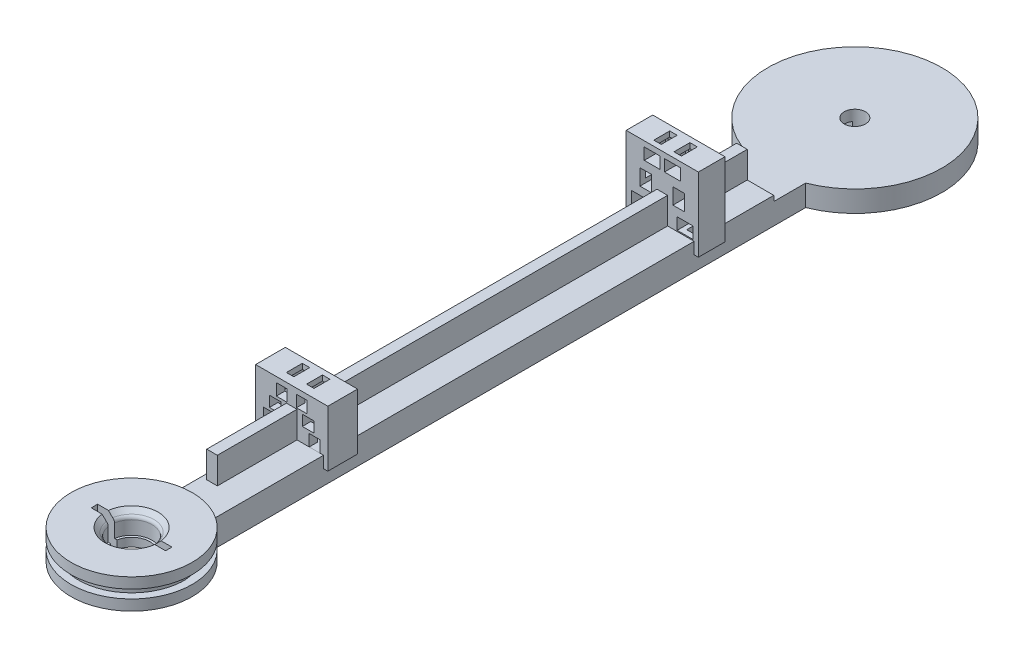
from build123d import *

# Parameters (mm, degrees)
SKETCH1_R                       = 5
ELBOWPULLEYMIDSECTION_DEPTH     = 0.8
SKETCH8_R                       = 1.925
BALLBEARINGSLOT_DEPTH           = 9.533463541
BALLBEARINGSTOPPER_START        = -0.8
SKETCH10_R                      = 1.925
SKETCH10_R_2                    = 1.7
BALLBEARINGSTOPPER_DEPTH        = 0.8
SKETCH25_W                      = 3.5
SKETCH25_H                      = 0.6
DEFORMATIONCUT_DEPTH            = 9.533463541
CIRPATTERN1_COUNT               = 2
CABLESLOT_DEPTH                 = 0.8
BONE_DEPTH                      = 1.25
CLEARANCECUT_REACH              = 62.794
CABLECLEARANCECUT_START         = -1.65
CABLECLEARANCECUT_DEPTH         = 0.8
FINGERHOLDERMOUTH_START         = -1.25
FINGERHOLDERMOUTH_DEPTH         = 2
SKETCH18_R                      = 1
FINGERAXLEHOLE_DEPTH            = 2
FINGERAXLELOCK_DEPTH            = 1
SKETCH19_W                      = 6.8
SKETCH19_H                      = 4.2
TUBECLIPSHOLDERBASE_DEPTH       = 2.8
TUBECLIPENTRANCES_START         = -0.8
SKETCH19_3_W                    = 0.25
SKETCH19_3_H                    = 1.1
SKETCH19_3_W_2                  = 1.1
SKETCH19_3_H_2                  = 1
TUBECLIPENTRANCES_DEPTH         = 2
SKETCH19_4_W                    = 1.1
SKETCH19_4_H                    = 1
CABLEEXITS_DEPTH                = 2.8
SKETCH32_W                      = 0.7
SKETCH32_H                      = 1.5
MIDDLELOCKSLOT_DEPTH            = 0.6
SKETCH33_W                      = 0.7
SKETCH33_H                      = 1.5
UPPERLOCKSLOT_DEPTH             = 0.5
SKETCH34_W                      = 0.7
SKETCH34_H                      = 1.5
LOWERLOCKSLOT_DEPTH             = 0.6
SKETCH43_W                      = 0.4
SKETCH43_H                      = 2.8
TUBECLIPSHOLDEREXTENSION_DEPTH  = 1.1
FINGERPULLEYCLEARANCECUT_DEPTH  = 0.5
SKETCH22_W                      = 6.8
SKETCH22_H                      = 5.85
TUBECLIPSHOLDERBASE2_DEPTH      = 2.5
TUBECLIPENTRANCES2_START        = -0.5
SKETCH22_3_W                    = 1.1
SKETCH22_3_H                    = 0.25
SKETCH22_3_H_2                  = 1
SKETCH22_3_W_2                  = 1
SKETCH22_3_H_3                  = 1.1
SKETCH22_3_W_3                  = 0.25
TUBECLIPENTRANCES2_DEPTH        = 2
SKETCH22_4_W                    = 1
SKETCH22_4_H                    = 1.1
SKETCH22_4_W_2                  = 1.1
SKETCH22_4_H_2                  = 1
CABLEEXITS2_DEPTH               = 2.5
SKETCH36_W                      = 0.7
SKETCH36_H                      = 1.5
LOWERLOCKSLOT2_DEPTH            = 0.6
SKETCH37_W                      = 1.5
SKETCH37_H                      = 0.7
MIDDLELOCKSLOT2_DEPTH           = 0.6
SKETCH38_W                      = 0.7
SKETCH38_H                      = 1.5
UPPERLOCKSLOT2_DEPTH            = 0.5
SKETCH39_W                      = 0.4
SKETCH39_H                      = 2.5
TUBECLIPSHOLDER2EXTENSION_DEPTH = 1.1
STIFFENERRIB_REACH              = 71.617
SKETCH26_W                      = 1
SKETCH26_H                      = 2.5
SPLIT1_SURFACE_1_1_BACK         = 85.055
SPLIT1_SURFACE_1_1_DEPTH        = 170.11
SPLIT1_SURFACE_1_2_BACK         = 85.055
SPLIT1_SURFACE_1_2_DEPTH        = 170.11
SPLIT1_SURFACE_2_3_BACK         = 85.055
SPLIT1_SURFACE_2_3_DEPTH        = 170.11
SPLIT1_SURFACE_2_4_BACK         = 85.055
SPLIT1_SURFACE_2_4_DEPTH        = 170.11


with BuildPart() as part:
    # Sketch1 → ElbowPulleyMidSection (new body)
    with BuildSketch(Plane(origin=(0, 0, 0), x_dir=(1, 0, 0), z_dir=(0, 1, 0))):
        with Locations(Location((0, 0, 0), (0, 0, 270))):
            Circle(SKETCH1_R)
    extrude(amount=ELBOWPULLEYMIDSECTION_DEPTH)

    # Sketch2 → Cap (revolve)
    with BuildSketch(Plane(origin=(0, 0, 0), x_dir=(0, 0, -1), z_dir=(1, 0, 0))):
        Polygon((0, 0.8), (5, 0.8), (5.7, 1.4), (5.7, 1.8), (0, 1.8), align=None)
        Polygon((5, 0.8), (5.7, 0.8), (5.7, 1.4), align=None)
    cap = revolve(axis=Axis((0, 0.8, 0), (0, 1, 0)))

    # Cap2: Cap across plane
    add(cap.mirror(Plane.ZX.offset(0.4)))

    # Sketch8 → BallBearingSlot (cut, through all)
    with BuildSketch(Plane(origin=(0, 1.8, 0), x_dir=(1, 0, 0), z_dir=(0, 1, 0))):
        with Locations(Location((0, 0, 0), (0, 0, 270))):
            Circle(SKETCH8_R)
    extrude(amount=-BALLBEARINGSLOT_DEPTH, mode=Mode.SUBTRACT)

    # Sketch10 → BallBearingStopper (add)
    with BuildSketch(Plane.XZ.offset(1).offset(BALLBEARINGSTOPPER_START)):
        with Locations(Location((0, 0, 0), (0, 0, 90))):
            Circle(SKETCH10_R)
        with Locations(Location((0, 0, 0), (0, 0, 270))):
            Circle(SKETCH10_R_2, mode=Mode.SUBTRACT)
    extrude(amount=BALLBEARINGSTOPPER_DEPTH)

    # Sketch11 → BearingInsertionSlope (revolve, cut)
    with BuildSketch(Plane(origin=(0, 0, 0), x_dir=(0, 0, -1), z_dir=(1, 0, 0))):
        with BuildLine():
            Line((2.5, 1.8), (1.925, 1.8))
            Line((1.925, 1.8), (1.925, 1.069281086))
            ThreePointArc((1.925, 1.069281086), (1.971446609, 1.256363955), (2.1, 1.4))
            Line((2.1, 1.4), (2.5, 1.8))
        make_face()
    revolve(axis=Axis((0, 0, 0), (0, 1, 0)), mode=Mode.SUBTRACT)

    # Sketch25 → DeformationCut (cut, through all)
    with BuildSketch(Plane(origin=(0, 1.8, 0), x_dir=(1, 0, 0), z_dir=(0, 1, 0))):
        with Locations((1.75, 0)):
            Rectangle(SKETCH25_W, SKETCH25_H)
    deformationcut = extrude(amount=-DEFORMATIONCUT_DEPTH, mode=Mode.SUBTRACT)

    # CirPattern1: DeformationCut ×2 about axis
    cirpattern1_axis = Axis((0, 0, 0), (0, 1, 0))
    for i in range(1, CIRPATTERN1_COUNT):
        add(deformationcut.rotate(cirpattern1_axis, i * 360 / CIRPATTERN1_COUNT), mode=Mode.SUBTRACT)

    # Sketch42 → CableSlot (cut)
    with BuildSketch(Plane(origin=(0, 0, 0), x_dir=(1, 0, 0), z_dir=(0, 1, 0))):
        with BuildLine():
            Line((-2.563034344, 2.846212677), (-2.563034344, 2.9))
            Line((-2.563034344, 2.9), (-4.073082371, 2.9))
            ThreePointArc((-4.073082371, 2.9), (-4.799215517, 1.402686858), (-4.993746089, -0.25))
            ThreePointArc((-4.993746089, -0.25), (-4.357203665, 1.752509441), (-2.563034344, 2.846212677))
        make_face()
        with BuildLine():
            Line((-4.073082371, 2.9), (-2.563034344, 2.9))
            Line((-2.563034344, 2.9), (-2.563034344, 3.7))
            Line((-2.563034344, 3.7), (-3.363034344, 3.7))
            ThreePointArc((-3.363034344, 3.7), (-3.739513063, 3.319042339), (-4.073082371, 2.9))
        make_face()
        with BuildLine():
            Line((2.563034344, 3.7), (2.563034344, 2.9))
            Line((2.563034344, 2.9), (3.756327994, 2.9))
            Line((3.756327994, 2.9), (4.073082371, 2.9))
            ThreePointArc((4.073082371, 2.9), (3.739513063, 3.319042339), (3.363034344, 3.7))
            Line((3.363034344, 3.7), (2.563034344, 3.7))
        make_face()
        with BuildLine():
            Line((3.756327994, 2.9), (2.563034344, 2.9))
            Line((2.563034344, 2.9), (2.563034344, 2.846212677))
            ThreePointArc((2.563034344, 2.846212677), (4.357203665, 1.752509441), (4.993746089, -0.25))
            ThreePointArc((4.993746089, -0.25), (4.998436278, -0.125039105), (5, 0))
            ThreePointArc((5, 0), (4.762636447, 1.522266098), (4.073082371, 2.9))
            Line((4.073082371, 2.9), (3.756327994, 2.9))
        make_face()
    extrude(amount=CABLESLOT_DEPTH, mode=Mode.SUBTRACT)

    # Sketch12 → Bone (add, symmetric)
    with BuildSketch(Plane(origin=(0, 0.4, 0), x_dir=(1, 0, 0), z_dir=(0, 1, 0))):
        with BuildLine():
            Line((0, 59.9), (0, 5.7))
            ThreePointArc((0, 5.7), (1.559503854, 5.482512903), (3, 4.846648326))
            Line((3, 4.846648326), (3, 60.468486389))
            ThreePointArc((3, 60.468486389), (1.526693877, 60.043375036), (0, 59.9))
        make_face()
        with BuildLine():
            ThreePointArc((-3, 4.846648326), (-1.559503854, 5.482512903), (0, 5.7))
            Line((0, 5.7), (0, 59.9))
            ThreePointArc((0, 59.9), (-1.526693877, 60.043375036), (-3, 60.468486389))
            Line((-3, 60.468486389), (-3, 4.846648326))
        make_face()
    extrude(amount=BONE_DEPTH, both=True)

    # ClearanceCut: up to this face of the body (flat: up to its plane)
    clearancecut_end = Plane(part.part.faces().sort_by_distance((0, -0.85, -32.755402086))[0])
    # Sketch15 → ClearanceCut (cut, up to the picked face)
    with BuildSketch(Plane(origin=(0, 1.65, 0), x_dir=(1, 0, 0), z_dir=(0, 1, 0)), mode=Mode.PRIVATE) as clearancecut_sk1:
        with BuildLine():
            Line((-3, 11.611595139), (-3, 4.846648326))
            ThreePointArc((-3, 4.846648326), (-2.036243086, 5.323881488), (-1, 5.611595139))
            Line((-1, 5.611595139), (-1, 11.611595139))
            Line((-1, 11.611595139), (-3, 11.611595139))
        make_face()
    clearancecut_tool1 = split(extrude(clearancecut_sk1.sketch, amount=-CLEARANCECUT_REACH, mode=Mode.PRIVATE), bisect_by=clearancecut_end, keep=Keep.BOTH, mode=Mode.PRIVATE)
    # Sketch15 → ClearanceCut (cut, up to the picked face)
    with BuildSketch(Plane(origin=(0, 1.65, 0), x_dir=(1, 0, 0), z_dir=(0, 1, 0)), mode=Mode.PRIVATE) as clearancecut_sk2:
        with BuildLine():
            Line((-3, 15.075696754), (-3, 11.611595139))
            Line((-3, 11.611595139), (-1, 11.611595139))
            ThreePointArc((-1, 11.611595139), (-1.535898385, 13.611595139), (-3, 15.075696754))
        make_face()
    clearancecut_tool2 = split(extrude(clearancecut_sk2.sketch, amount=-CLEARANCECUT_REACH, mode=Mode.PRIVATE), bisect_by=clearancecut_end, keep=Keep.BOTH, mode=Mode.PRIVATE)
    add(clearancecut_tool1.solids().sort_by(Axis((-2.020038, 1.65, -8.452748), (0, -1, 0)))[0], mode=Mode.SUBTRACT)
    add(clearancecut_tool2.solids().sort_by(Axis((-2.179919, 1.65, -12.968407), (0, -1, 0)))[0], mode=Mode.SUBTRACT)

    # Sketch16 → CableClearanceCut (cut)
    with BuildSketch(Plane(origin=(0, 1.65, 0), x_dir=(1, 0, 0), z_dir=(0, 1, 0)).offset(CABLECLEARANCECUT_START)):
        with BuildLine():
            Line((-1, 5.611595139), (-1, 9.111595139))
            Line((-1, 9.111595139), (3, 4.846648326))
            ThreePointArc((3, 4.846648326), (1.070647424, 5.598545712), (-1, 5.611595139))
        make_face()
    extrude(amount=CABLECLEARANCECUT_DEPTH, mode=Mode.SUBTRACT)

    # Sketch12_3 → FingerHolderMouth (add)
    with BuildSketch(Plane(origin=(0, 0.4, 0), x_dir=(1, 0, 0), z_dir=(0, 1, 0)).offset(FINGERHOLDERMOUTH_START)):
        with BuildLine():
            ThreePointArc((-3, 60.468486389), (0, 59.9), (3, 60.468486389))
            ThreePointArc((3, 60.468486389), (6.776429738, 63.482641448), (8.2, 68.1))
            ThreePointArc((8.2, 68.1), (-4.617358552, 74.876429738), (-3, 60.468486389))
        make_face()
    extrude(amount=FINGERHOLDERMOUTH_DEPTH)

    # Sketch18 → FingerAxleHole (cut)
    with BuildSketch(Plane.XZ.offset(0.85)):
        with Locations(Location((0, -68.1, 0), (0, 0, 270))):
            Circle(SKETCH18_R)
    extrude(amount=-FINGERAXLEHOLE_DEPTH, mode=Mode.SUBTRACT)

    # Sketch24 → FingerAxleLock (cut)
    with BuildSketch(Plane.XZ.offset(0.85)):
        Polygon((0, -68.7), (2, -68.7), (2, -67.5), (0, -67.5), (-2, -67.5), (-2, -68.7), align=None)
    extrude(amount=-FINGERAXLELOCK_DEPTH, mode=Mode.SUBTRACT)

    # Sketch19 → TubeClipsHolderBase (add)
    with BuildSketch(Plane.XY.offset(-15.075696754)):
        with Locations((0, 3.75)):
            Rectangle(SKETCH19_W, SKETCH19_H)
    extrude(amount=-TUBECLIPSHOLDERBASE_DEPTH)

    # Sketch19_3 → TubeClipEntrances (cut)
    with BuildSketch(Plane.XY.offset(-15.075696754).offset(TUBECLIPENTRANCES_START)):
        with Locations((-2.775, 2.2)):
            Rectangle(SKETCH19_3_W, SKETCH19_3_H)
        Polygon((-2.65, 2.75), (-2.65, 1.65), (-1.65, 1.65), (-1.65, 2.75), (-2.1, 2.75), align=None)
        with Locations((-1.525, 2.2)):
            Rectangle(SKETCH19_3_W, SKETCH19_3_H)
        Polygon((-2.1, 2.75), (-1.65, 2.75), (-1.4, 2.75), (-1, 2.75), (-1, 3), (-2.1, 3), align=None)
        with Locations((-1.55, 3.5)):
            Rectangle(SKETCH19_3_W_2, SKETCH19_3_H_2)
        Polygon((-2.1, 4.25), (-2.1, 4), (-1, 4), (-1, 4.25), (-1.45, 4.25), (-1.7, 4.25), align=None)
        with Locations((-1.575, 4.8)):
            Rectangle(SKETCH19_3_W, SKETCH19_3_H)
        Polygon((-1.45, 4.25), (-1, 4.25), (-0.45, 4.25), (-0.45, 5.35), (-1.45, 5.35), align=None)
        with Locations((-0.325, 4.8)):
            Rectangle(SKETCH19_3_W, SKETCH19_3_H)
    tubeclipentrances = extrude(amount=-TUBECLIPENTRANCES_DEPTH, mode=Mode.SUBTRACT)

    # Sketch19_4 → CableExits (cut)
    with BuildSketch(Plane.XY.offset(-15.075696754)):
        Polygon((-2.65, 2.75), (-2.65, 1.65), (-1.65, 1.65), (-1.65, 2.75), (-2.1, 2.75), align=None)
        with Locations((-1.55, 3.5)):
            Rectangle(SKETCH19_4_W, SKETCH19_4_H)
        Polygon((-1.45, 4.25), (-1, 4.25), (-0.45, 4.25), (-0.45, 5.35), (-1.45, 5.35), align=None)
    cableexits = extrude(amount=-CABLEEXITS_DEPTH, mode=Mode.SUBTRACT)

    # Sketch32 → MiddleLockSlot (cut)
    with BuildSketch(Plane(origin=(-2.1, 6.85, 0), x_dir=(0, 1, 0), z_dir=(1, 0, 0))):
        with Locations((-3.35, -16.625696754)):
            Rectangle(SKETCH32_W, SKETCH32_H)
    middlelockslot = extrude(amount=-MIDDLELOCKSLOT_DEPTH, mode=Mode.SUBTRACT)

    # Sketch33 → UpperLockSlot (cut)
    with BuildSketch(Plane.XZ.offset(-5.35)):
        with Locations((-0.95, -16.625696754)):
            Rectangle(SKETCH33_W, SKETCH33_H)
    upperlockslot = extrude(amount=-UPPERLOCKSLOT_DEPTH, mode=Mode.SUBTRACT)

    # Sketch34 → LowerLockSlot (cut)
    with BuildSketch(Plane(origin=(0, 1.65, 0), x_dir=(1, 0, 0), z_dir=(0, 1, 0))):
        with Locations((-2.15, 16.625696754)):
            Rectangle(SKETCH34_W, SKETCH34_H)
    lowerlockslot = extrude(amount=-LOWERLOCKSLOT_DEPTH, mode=Mode.SUBTRACT)

    # MirroredTubeClipSlots: TubeClipEntrances, CableExits, MiddleLockSlot, UpperLockSlot, LowerLockSlot across plane
    add(tubeclipentrances.mirror(Plane(origin=(0, 0, 0), x_dir=(0, 0, 1), z_dir=(1, 0, 0))), mode=Mode.SUBTRACT)
    add(cableexits.mirror(Plane(origin=(0, 0, 0), x_dir=(0, 0, 1), z_dir=(1, 0, 0))), mode=Mode.SUBTRACT)
    add(middlelockslot.mirror(Plane(origin=(0, 0, 0), x_dir=(0, 0, 1), z_dir=(1, 0, 0))), mode=Mode.SUBTRACT)
    add(upperlockslot.mirror(Plane(origin=(0, 0, 0), x_dir=(0, 0, 1), z_dir=(1, 0, 0))), mode=Mode.SUBTRACT)
    add(lowerlockslot.mirror(Plane(origin=(0, 0, 0), x_dir=(0, 0, 1), z_dir=(1, 0, 0))), mode=Mode.SUBTRACT)

    # Sketch43 → TubeClipsHolderExtension (add)
    with BuildSketch(Plane.XZ.offset(-1.65)):
        with Locations((3.2, -16.475696754)):
            Rectangle(SKETCH43_W, SKETCH43_H)
        with Locations((-3.2, -16.475696754)):
            Rectangle(SKETCH43_W, SKETCH43_H)
    extrude(amount=TUBECLIPSHOLDEREXTENSION_DEPTH)

    # Sketch21 → FingerPulleyClearanceCut (cut)
    with BuildSketch(Plane(origin=(0, 1.65, 0), x_dir=(1, 0, 0), z_dir=(0, 1, 0))):
        with BuildLine():
            Line((-3, 60.468486389), (-3, 57.468486389))
            Line((-3, 57.468486389), (3, 57.468486389))
            Line((3, 57.468486389), (3, 60.468486389))
            ThreePointArc((3, 60.468486389), (0, 59.9), (-3, 60.468486389))
        make_face()
    extrude(amount=-FINGERPULLEYCLEARANCECUT_DEPTH, mode=Mode.SUBTRACT)

    # Sketch22 → TubeClipsHolderBase2 (add)
    with BuildSketch(Plane(origin=(0, 0, -52.468486389), x_dir=(-1, 0, 0), z_dir=(0, 0, -1))):
        with Locations((0, 4.575)):
            Rectangle(SKETCH22_W, SKETCH22_H)
    extrude(amount=-TUBECLIPSHOLDERBASE2_DEPTH)

    # Sketch22_3 → TubeClipEntrances2 (cut)
    with BuildSketch(Plane(origin=(0, 0, -52.468486389), x_dir=(-1, 0, 0), z_dir=(0, 0, -1)).offset(TUBECLIPENTRANCES2_START)):
        with Locations((-1.55, 4.975)):
            Rectangle(SKETCH22_3_W, SKETCH22_3_H)
        with Locations((-1.55, 4.35)):
            Rectangle(SKETCH22_3_W, SKETCH22_3_H_2)
        with Locations((-1.55, 3.725)):
            Rectangle(SKETCH22_3_W, SKETCH22_3_H)
        with Locations((-2.15, 2.3)):
            Rectangle(SKETCH22_3_W_2, SKETCH22_3_H_3)
        with Locations((-2.775, 2.3)):
            Rectangle(SKETCH22_3_W_3, SKETCH22_3_H_3)
        with Locations((-1.525, 2.3)):
            Rectangle(SKETCH22_3_W_3, SKETCH22_3_H_3)
        with Locations((-0.95, 6.45)):
            Rectangle(SKETCH22_3_W_2, SKETCH22_3_H_3)
        with Locations((-1.575, 6.45)):
            Rectangle(SKETCH22_3_W_3, SKETCH22_3_H_3)
        with Locations((-0.325, 6.45)):
            Rectangle(SKETCH22_3_W_3, SKETCH22_3_H_3)
    tubeclipentrances2 = extrude(amount=-TUBECLIPENTRANCES2_DEPTH, mode=Mode.SUBTRACT)

    # Sketch22_4 → CableExits2 (cut)
    with BuildSketch(Plane(origin=(0, 0, -52.468486389), x_dir=(-1, 0, 0), z_dir=(0, 0, -1))):
        with Locations((-2.15, 2.3)):
            Rectangle(SKETCH22_4_W, SKETCH22_4_H)
        with Locations((-1.55, 4.35)):
            Rectangle(SKETCH22_4_W_2, SKETCH22_4_H_2)
        with Locations((-0.95, 6.45)):
            Rectangle(SKETCH22_4_W, SKETCH22_4_H)
    cableexits2 = extrude(amount=-CABLEEXITS2_DEPTH, mode=Mode.SUBTRACT)

    # Sketch36 → LowerLockSlot2 (cut)
    with BuildSketch(Plane(origin=(0, 1.75, 0), x_dir=(1, 0, 0), z_dir=(0, 1, 0))):
        with Locations((2.15, 51.218486389)):
            Rectangle(SKETCH36_W, SKETCH36_H)
    lowerlockslot2 = extrude(amount=-LOWERLOCKSLOT2_DEPTH, mode=Mode.SUBTRACT)

    # Sketch37 → MiddleLockSlot2 (cut)
    with BuildSketch(Plane.ZY.offset(-2.1)):
        with Locations((-51.218486389, 4.35)):
            Rectangle(SKETCH37_W, SKETCH37_H)
    middlelockslot2 = extrude(amount=-MIDDLELOCKSLOT2_DEPTH, mode=Mode.SUBTRACT)

    # Sketch38 → UpperLockSlot2 (cut)
    with BuildSketch(Plane.XZ.offset(-7)):
        with Locations((0.95, -51.218486389)):
            Rectangle(SKETCH38_W, SKETCH38_H)
    upperlockslot2 = extrude(amount=-UPPERLOCKSLOT2_DEPTH, mode=Mode.SUBTRACT)

    # MirroredTubeClipSlots2: TubeClipEntrances2, CableExits2, LowerLockSlot2, MiddleLockSlot2, UpperLockSlot2 across plane
    add(tubeclipentrances2.mirror(Plane(origin=(0, 0, 0), x_dir=(0, 0, 1), z_dir=(1, 0, 0))), mode=Mode.SUBTRACT)
    add(cableexits2.mirror(Plane(origin=(0, 0, 0), x_dir=(0, 0, 1), z_dir=(1, 0, 0))), mode=Mode.SUBTRACT)
    add(lowerlockslot2.mirror(Plane(origin=(0, 0, 0), x_dir=(0, 0, 1), z_dir=(1, 0, 0))), mode=Mode.SUBTRACT)
    add(middlelockslot2.mirror(Plane(origin=(0, 0, 0), x_dir=(0, 0, 1), z_dir=(1, 0, 0))), mode=Mode.SUBTRACT)
    add(upperlockslot2.mirror(Plane(origin=(0, 0, 0), x_dir=(0, 0, 1), z_dir=(1, 0, 0))), mode=Mode.SUBTRACT)

    # Sketch39 → TubeClipsHolder2Extension (add)
    with BuildSketch(Plane.XZ.offset(-1.65)):
        with Locations((3.2, -51.218486389)):
            Rectangle(SKETCH39_W, SKETCH39_H)
        with Locations((-3.2, -51.218486389)):
            Rectangle(SKETCH39_W, SKETCH39_H)
    extrude(amount=TUBECLIPSHOLDER2EXTENSION_DEPTH)

    # StiffenerRib: up to this face of the body (flat: up to its plane)
    stiffenerrib_end = Plane(part.part.faces().sort_by_distance((0, 1.4, -57.468486389))[0])
    # Sketch26 → StiffenerRib (add, up to the picked face)
    with BuildSketch(Plane(origin=(0, 0, -7.575696754), x_dir=(-1, 0, 0), z_dir=(0, 0, -1)), mode=Mode.PRIVATE) as stiffenerrib_sk1:
        with Locations((0, 2.9)):
            Rectangle(SKETCH26_W, SKETCH26_H)
    stiffenerrib_tool1 = split(extrude(stiffenerrib_sk1.sketch, amount=STIFFENERRIB_REACH, mode=Mode.PRIVATE), bisect_by=stiffenerrib_end, keep=Keep.BOTH, mode=Mode.PRIVATE)
    add(stiffenerrib_tool1.solids().sort_by(Axis((0, 2.9, -7.575697), (0, 0, -1)))[0])


with BuildPart() as body_2:
    # Split1: the piece behind the surface
    add(part.part)
    # Split1 surface 1: a surface, the sketch's curves swept straight by 170.11 mm
    with BuildLine(Plane(origin=(3.4, 0, 0), x_dir=(0, 0, -1), z_dir=(1, 0, 0)).offset(-SPLIT1_SURFACE_1_1_BACK), mode=Mode.PRIVATE) as split1_surface_1_1_path:
        Line((49.968486389, 0.55), (52.468486389, 0.55))
        Line((52.468486389, 0.55), (52.468486389, 7.5))
        Line((52.468486389, 7.5), (49.968486389, 7.5))
        Line((49.968486389, 7.5), (49.968486389, 0.55))
    split1_surface_1_1 = Shell.extrude(split1_surface_1_1_path.wire(), (1 * SPLIT1_SURFACE_1_1_DEPTH, 0 * SPLIT1_SURFACE_1_1_DEPTH, 0 * SPLIT1_SURFACE_1_1_DEPTH))
    split(bisect_by=split1_surface_1_1, keep=Keep.BOTTOM)


with BuildPart() as part_1:
    add(part.part)

    # Split1: split by a surface, the side it looks to stays
    # Split1 surface 1: a surface, the sketch's curves swept straight by 170.11 mm
    with BuildLine(Plane(origin=(3.4, 0, 0), x_dir=(0, 0, -1), z_dir=(1, 0, 0)).offset(-SPLIT1_SURFACE_1_2_BACK), mode=Mode.PRIVATE) as split1_surface_1_2_path:
        Line((49.968486389, 0.55), (52.468486389, 0.55))
        Line((52.468486389, 0.55), (52.468486389, 7.5))
        Line((52.468486389, 7.5), (49.968486389, 7.5))
        Line((49.968486389, 7.5), (49.968486389, 0.55))
    split1_surface_1_2 = Shell.extrude(split1_surface_1_2_path.wire(), (1 * SPLIT1_SURFACE_1_2_DEPTH, 0 * SPLIT1_SURFACE_1_2_DEPTH, 0 * SPLIT1_SURFACE_1_2_DEPTH))
    split(bisect_by=split1_surface_1_2, keep=Keep.TOP)


with BuildPart() as body_3:
    # Split1 2 body 2: the piece behind the surface
    add(body_2.part)
    # Split1 surface 2: a surface, the sketch's curves swept straight by 170.11 mm
    with BuildLine(Plane(origin=(3.4, 0, 0), x_dir=(0, 0, -1), z_dir=(1, 0, 0)).offset(-SPLIT1_SURFACE_2_3_BACK), mode=Mode.PRIVATE) as split1_surface_2_3_path:
        Line((17.875696754, 5.85), (15.075696754, 5.85))
        Line((15.075696754, 5.85), (15.075696754, 0.55))
        Line((15.075696754, 0.55), (17.875696754, 0.55))
        Line((17.875696754, 0.55), (17.875696754, 5.85))
    split1_surface_2_3 = Shell.extrude(split1_surface_2_3_path.wire(), (1 * SPLIT1_SURFACE_2_3_DEPTH, 0 * SPLIT1_SURFACE_2_3_DEPTH, 0 * SPLIT1_SURFACE_2_3_DEPTH))
    split(bisect_by=split1_surface_2_3, keep=Keep.BOTTOM)


with BuildPart() as body_2_1:
    add(body_2.part)

    # Split1 2 body 2: split by a surface, the side it looks to stays
    # Split1 surface 2: a surface, the sketch's curves swept straight by 170.11 mm
    with BuildLine(Plane(origin=(3.4, 0, 0), x_dir=(0, 0, -1), z_dir=(1, 0, 0)).offset(-SPLIT1_SURFACE_2_4_BACK), mode=Mode.PRIVATE) as split1_surface_2_4_path:
        Line((17.875696754, 5.85), (15.075696754, 5.85))
        Line((15.075696754, 5.85), (15.075696754, 0.55))
        Line((15.075696754, 0.55), (17.875696754, 0.55))
        Line((17.875696754, 0.55), (17.875696754, 5.85))
    split1_surface_2_4 = Shell.extrude(split1_surface_2_4_path.wire(), (1 * SPLIT1_SURFACE_2_4_DEPTH, 0 * SPLIT1_SURFACE_2_4_DEPTH, 0 * SPLIT1_SURFACE_2_4_DEPTH))
    split(bisect_by=split1_surface_2_4, keep=Keep.TOP)


solid = Compound([part_1.part, body_3.part, body_2_1.part])
